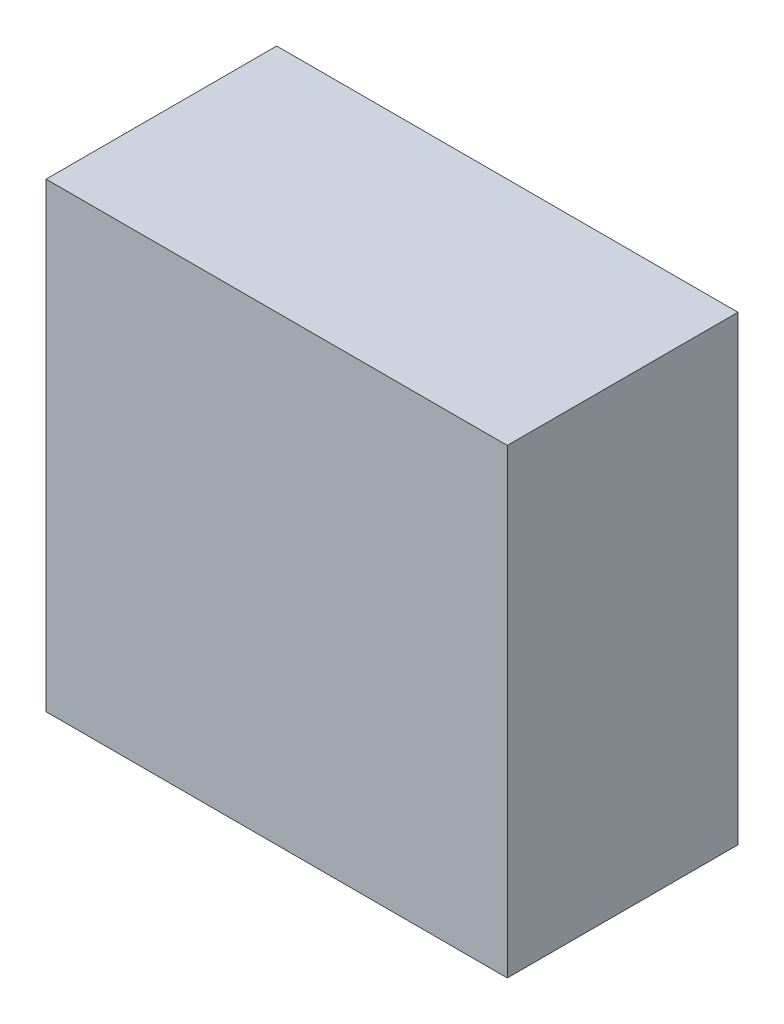
from build123d import *

# Parameters (mm, degrees)
SKETCH1_W           = 127
SKETCH1_H           = 127
BOSS_EXTRUDE1_DEPTH = 63.5
SKETCH2_R           = 12.7
BOSS_EXTRUDE2_DEPTH = 50.8


with BuildPart() as part:
    # Sketch1 → Boss-Extrude1 (new body)
    with BuildSketch(Plane.XY):
        Rectangle(SKETCH1_W, SKETCH1_H)
    extrude(amount=BOSS_EXTRUDE1_DEPTH)

    # Sketch2 → Boss-Extrude2 (add)
    with BuildSketch(Plane(origin=(0, 0, 0), x_dir=(-1, 0, 0), z_dir=(0, 0, -1))):
        Circle(SKETCH2_R)
    extrude(amount=BOSS_EXTRUDE2_DEPTH)


solid = part.part
